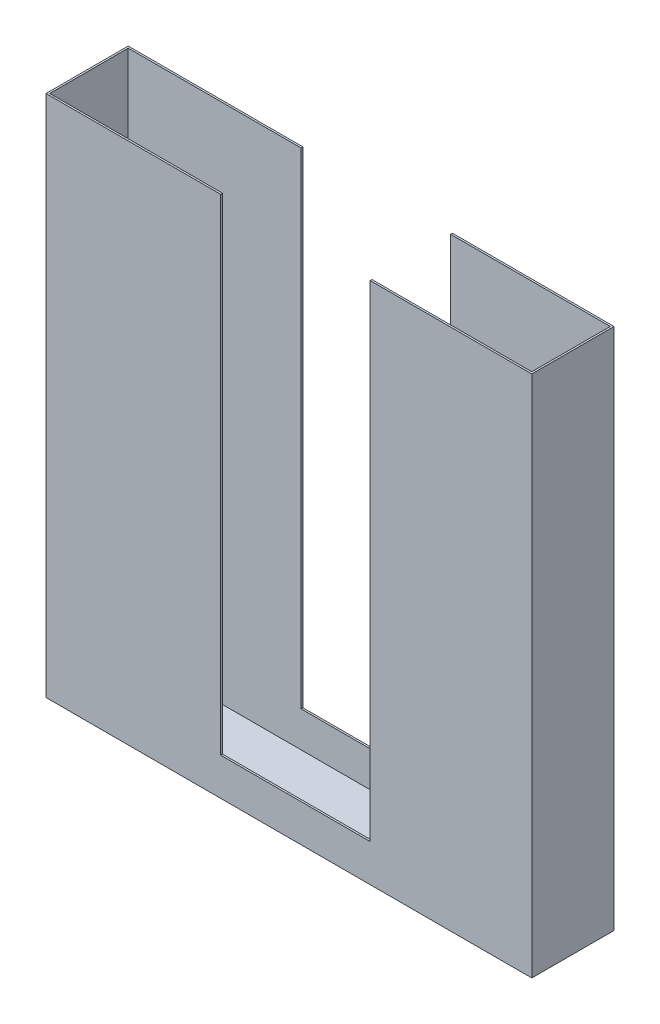
from build123d import *

# Parameters (mm, degrees)
SKETCH2_W           = 412.75
SKETCH2_H           = 444.5
BOSS_EXTRUDE1_DEPTH = 69.85
SHELL1_T            = -1.5875
SKETCH4_W           = 127
SKETCH4_H           = 412.75
CUT_EXTRUDE1_DEPTH  = 69.85


with BuildPart() as part:
    # Sketch2 → Boss-Extrude1 (new body)
    with BuildSketch(Plane.XY):
        with Locations((87.819148936, -186.024601064)):
            Rectangle(SKETCH2_W, SKETCH2_H)
    extrude(amount=BOSS_EXTRUDE1_DEPTH)

    # Shell1
    shell1_openings = [part.faces().sort_by_distance(p)[0] for p in [
        (87.819148936, 36.225398936, 34.925),
    ]]
    offset(amount=SHELL1_T, openings=shell1_openings, kind=Kind.INTERSECTION)

    # Sketch4 → Cut-Extrude1 (cut)
    with BuildSketch(Plane.XY.offset(69.85)):
        with Locations((93.402369386, -170.125111794)):
            Rectangle(SKETCH4_W, SKETCH4_H)
    extrude(amount=-CUT_EXTRUDE1_DEPTH, mode=Mode.SUBTRACT)


solid = part.part
